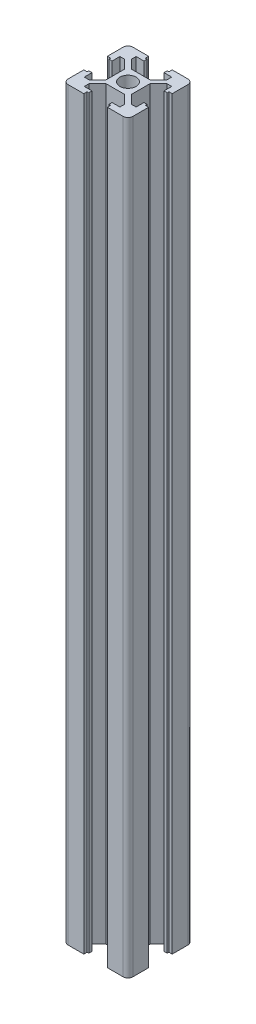
from build123d import *

# Parameters (mm, degrees)
SKETCH_1_R      = 2.5
EXTRUDE_1_DEPTH = 230
FILLET_1_R      = 1.5


with BuildPart() as part:
    # 草图1 → 凸台-拉伸1 (new body)
    with BuildSketch(Plane(origin=(0, 0, 0), x_dir=(1, 0, 0), z_dir=(0, 1, 0))):
        Polygon((3.9, 2.839339828), (3.9, -2.839339828), (6.560660172, -5.5), (8, -5.5), (8, -3.1), (9, -3.1), (9, -3.65), (10, -3.65), (10, -10), (3.65, -10), (3.65, -9), (3.1, -9), (3.1, -8), (5.5, -8), (5.5, -6.560660172), (2.839339828, -3.9), (-2.839339828, -3.9), (-5.5, -6.560660172), (-5.5, -8), (-3.1, -8), (-3.1, -9), (-3.65, -9), (-3.65, -10), (-10, -10), (-10, -3.65), (-9, -3.65), (-9, -3.1), (-8, -3.1), (-8, -5.5), (-6.560660172, -5.5), (-3.9, -2.839339828), (-3.9, 2.839339828), (-6.560660172, 5.5), (-8, 5.5), (-8, 3.1), (-9, 3.1), (-9, 3.65), (-10, 3.65), (-10, 10), (-3.65, 10), (-3.65, 9), (-3.1, 9), (-3.1, 8), (-5.5, 8), (-5.5, 6.560660172), (-2.839339828, 3.9), (2.839339828, 3.9), (5.5, 6.560660172), (5.5, 8), (3.1, 8), (3.1, 9), (3.65, 9), (3.65, 10), (10, 10), (10, 3.65), (9, 3.65), (9, 3.1), (8, 3.1), (8, 5.5), (6.560660172, 5.5), align=None)
        Circle(SKETCH_1_R, mode=Mode.SUBTRACT)
    extrude(amount=EXTRUDE_1_DEPTH)

    # 圆角1
    fillet_1_edges = [part.edges().sort_by_distance(p)[0] for p in [
        (-10, 115, 10),
        (-10, 115, -10),
        (10, 115, -10),
        (10, 115, 10),
    ]]
    fillet(fillet_1_edges, radius=FILLET_1_R)


solid = part.part
